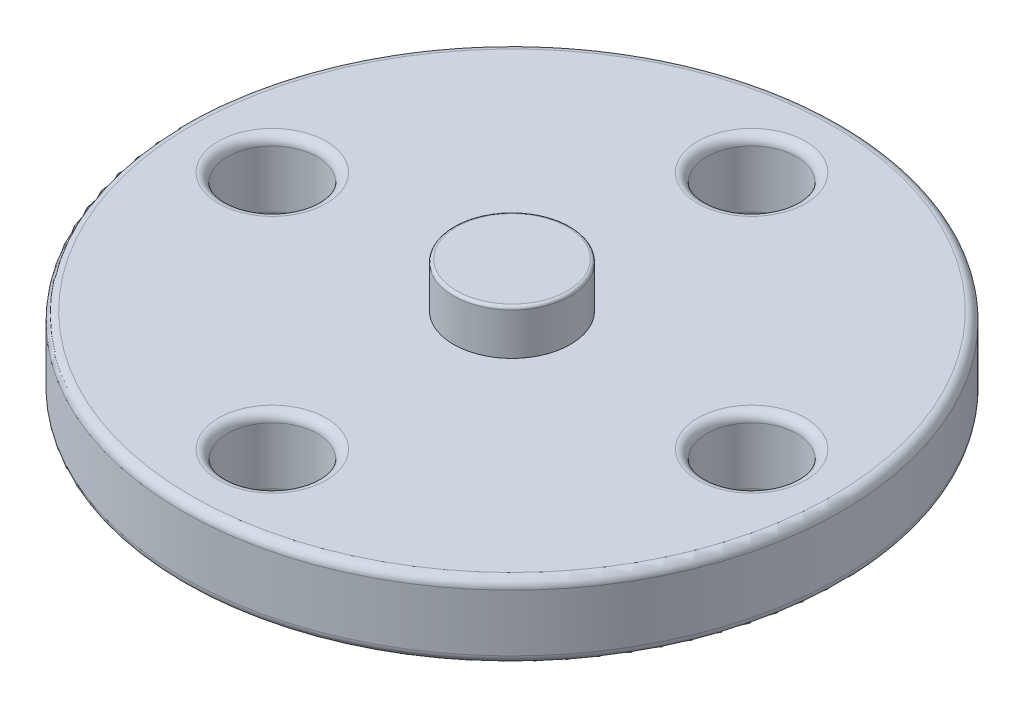
from build123d import *

# Parameters (mm, degrees)
SKETCH1_R           = 11
SKETCH1_R_2         = 1.5
BOSS_EXTRUDE1_DEPTH = 2.5
FILLET1_R           = 0.3
SKETCH2_R           = 1.95
BOSS_EXTRUDE2_DEPTH = 1.5
FILLET2_R           = 0.1


with BuildPart() as part:
    # Sketch1 → Boss-Extrude1 (new body)
    with BuildSketch(Plane(origin=(0, 0, 0), x_dir=(1, 0, 0), z_dir=(0, 1, 0))):
        Circle(SKETCH1_R)
        with Locations((-8, 0)):
            Circle(SKETCH1_R_2, mode=Mode.SUBTRACT)
        with Locations((0, 8)):
            Circle(SKETCH1_R_2, mode=Mode.SUBTRACT)
        with Locations((8, 0)):
            Circle(SKETCH1_R_2, mode=Mode.SUBTRACT)
        with Locations((0, -8)):
            Circle(SKETCH1_R_2, mode=Mode.SUBTRACT)
    extrude(amount=BOSS_EXTRUDE1_DEPTH)

    # Fillet1
    fillet1_edges = [part.edges().sort_by_distance(p)[0] for p in [
        (-1.5, 2.5, -8),
        (6.5, 2.5, 0),
        (-1.5, 2.5, 8),
        (-11, 2.5, 0),
        (-11, 0, 0),
        (-1.5, 0, 8),
        (6.5, 0, 0),
        (-9.5, 2.5, 0),
        (-1.5, 0, -8),
        (-9.5, 0, 0),
    ]]
    fillet(fillet1_edges, radius=FILLET1_R)

    # Sketch2 → Boss-Extrude2 (add)
    with BuildSketch(Plane(origin=(0, 2.5, 0), x_dir=(1, 0, 0), z_dir=(0, 1, 0))):
        Circle(SKETCH2_R)
    extrude(amount=BOSS_EXTRUDE2_DEPTH)

    # Fillet2
    fillet2_edges = [part.edges().sort_by_distance(p)[0] for p in [
        (-1.95, 4, 0),
    ]]
    fillet(fillet2_edges, radius=FILLET2_R)


solid = part.part
